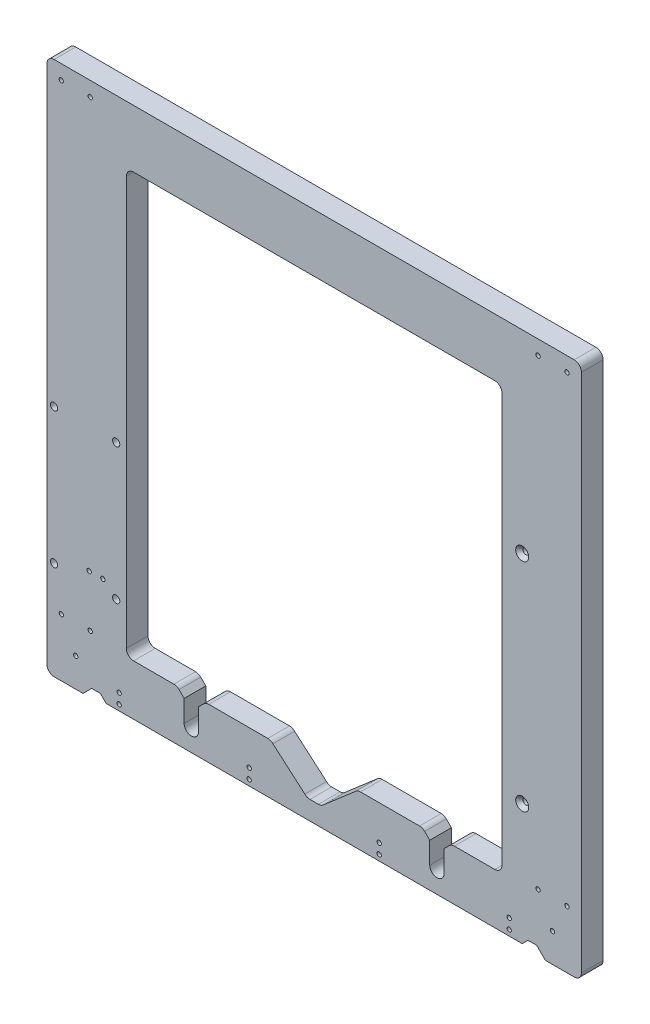
from build123d import *

# Parameters (mm, degrees)
MODEL_R                  = 1.5
MODEL_R_2                = 2
RESSALTO_EXTRUS_O1_DEPTH = 15
ESBO_O1_R                = 2.5
CORTE_EXTRUS_O1_DEPTH    = 10
ESBO_O2_R                = 2.5
CORTE_EXTRUS_O2_DEPTH    = 10
CHANFRO1_SIZE            = 2.5


with BuildPart() as part:
    # Model → Ressalto-extrusão1 (new body)
    with BuildSketch(Plane.XY):
        with BuildLine():
            Line((45.959420932, 55.536238099), (45.959420932, 415.536238099))
            ThreePointArc((45.959420932, 415.536238099), (47.423887026, 419.071772005), (50.959420932, 420.536238099))
            Line((50.959420932, 420.536238099), (410.959420932, 420.536238099))
            ThreePointArc((410.959420932, 420.536238099), (414.494954838, 419.071772005), (415.959420932, 415.536238099))
            Line((415.959420932, 415.536238099), (415.959420932, 55.536238099))
            ThreePointArc((415.959420932, 55.536238099), (414.494954838, 52.000704193), (410.959420932, 50.536238099))
            Line((410.959420932, 50.536238099), (390.959420932, 50.536238099))
            Line((390.959420932, 50.536238099), (388.959420932, 52.536238099))
            Line((388.959420932, 52.536238099), (384.959420932, 56.536238099))
            Line((384.959420932, 56.536238099), (378.959420932, 56.536238099))
            Line((378.959420932, 56.536238099), (374.959420932, 52.536238099))
            Line((374.959420932, 52.536238099), (86.959420932, 52.536238099))
            Line((86.959420932, 52.536238099), (82.959420932, 56.536238099))
            Line((82.959420932, 56.536238099), (76.959420932, 56.536238099))
            Line((76.959420932, 56.536238099), (72.959420932, 52.536238099))
            Line((72.959420932, 52.536238099), (70.959420932, 50.536238099))
            Line((70.959420932, 50.536238099), (50.959420932, 50.536238099))
            ThreePointArc((50.959420932, 50.536238099), (47.423887026, 52.000704193), (45.959420932, 55.536238099))
        make_face()
        with Locations((95.959420932, 56.536238099)):
            Circle(MODEL_R, mode=Mode.SUBTRACT)
        with Locations((365.959420932, 56.536238099)):
            Circle(MODEL_R, mode=Mode.SUBTRACT)
        with Locations((275.959420932, 56.536238099)):
            Circle(MODEL_R, mode=Mode.SUBTRACT)
        with Locations((185.959420932, 56.536238099)):
            Circle(MODEL_R, mode=Mode.SUBTRACT)
        with Locations((55.959420932, 90.536238099)):
            Circle(MODEL_R, mode=Mode.SUBTRACT)
        with Locations((75.959420932, 90.536238099)):
            Circle(MODEL_R, mode=Mode.SUBTRACT)
        with Locations((65.959420932, 70.536238099)):
            Circle(MODEL_R, mode=Mode.SUBTRACT)
        with Locations((395.959420932, 70.536238099)):
            Circle(MODEL_R, mode=Mode.SUBTRACT)
        with Locations((385.959420932, 90.536238099)):
            Circle(MODEL_R, mode=Mode.SUBTRACT)
        with Locations((405.959420932, 90.536238099)):
            Circle(MODEL_R, mode=Mode.SUBTRACT)
        with Locations((405.959420932, 410.536238099)):
            Circle(MODEL_R, mode=Mode.SUBTRACT)
        with Locations((385.959420932, 410.536238099)):
            Circle(MODEL_R, mode=Mode.SUBTRACT)
        with Locations((55.959420932, 410.536238099)):
            Circle(MODEL_R, mode=Mode.SUBTRACT)
        with Locations((75.959420932, 410.536238099)):
            Circle(MODEL_R, mode=Mode.SUBTRACT)
        with Locations((93.910965405, 118.501571518)):
            Circle(MODEL_R, mode=Mode.SUBTRACT)
        with Locations((50.910965405, 212.501571518)):
            Circle(MODEL_R, mode=Mode.SUBTRACT)
        with Locations((93.910965405, 212.501571518)):
            Circle(MODEL_R, mode=Mode.SUBTRACT)
        with Locations((50.876198806, 118.527793034)):
            Circle(MODEL_R, mode=Mode.SUBTRACT)
        with Locations((95.959420932, 63.536238099)):
            Circle(MODEL_R, mode=Mode.SUBTRACT)
        with Locations((365.959420932, 63.536238099)):
            Circle(MODEL_R, mode=Mode.SUBTRACT)
        with Locations((275.959420932, 63.536238099)):
            Circle(MODEL_R, mode=Mode.SUBTRACT)
        with Locations((185.959420932, 63.536238099)):
            Circle(MODEL_R, mode=Mode.SUBTRACT)
        with Locations((84.709420932, 126.036238099)):
            Circle(MODEL_R, mode=Mode.SUBTRACT)
        with Locations((75.209420932, 126.036238099)):
            Circle(MODEL_R, mode=Mode.SUBTRACT)
        with Locations((374.959420932, 136.436238099)):
            Circle(MODEL_R_2, mode=Mode.SUBTRACT)
        with Locations((374.959420932, 286.436238099)):
            Circle(MODEL_R_2, mode=Mode.SUBTRACT)
        with BuildLine():
            Line((140.959420932, 67.536238099), (140.959420932, 82.536238099))
            Line((140.959420932, 82.536238099), (137.423887026, 86.071772005))
            ThreePointArc((137.423887026, 86.071772005), (135.801770282, 87.155635761), (133.88835312, 87.536238099))
            Line((133.88835312, 87.536238099), (105.959420932, 87.536238099))
            ThreePointArc((105.959420932, 87.536238099), (102.423887026, 89.000704193), (100.959420932, 92.536238099))
            Line((100.959420932, 92.536238099), (100.959420932, 375.536238099))
            ThreePointArc((100.959420932, 375.536238099), (102.423887026, 379.071772005), (105.959420932, 380.536238099))
            Line((105.959420932, 380.536238099), (355.959420932, 380.536238099))
            ThreePointArc((355.959420932, 380.536238099), (359.494954838, 379.071772005), (360.959420932, 375.536238099))
            Line((360.959420932, 375.536238099), (360.959420932, 92.536238099))
            ThreePointArc((360.959420932, 92.536238099), (359.494954838, 89.000704193), (355.959420932, 87.536238099))
            Line((355.959420932, 87.536238099), (328.030488744, 87.536238099))
            ThreePointArc((328.030488744, 87.536238099), (326.117071582, 87.155635761), (324.494954838, 86.071772005))
            Line((324.494954838, 86.071772005), (320.959420932, 82.536238099))
            Line((320.959420932, 82.536238099), (320.959420932, 67.536238099))
            ThreePointArc((320.959420932, 67.536238099), (315.959420932, 62.536238099), (310.959420932, 67.536238099))
            Line((310.959420932, 67.536238099), (310.959420932, 82.536238099))
            Line((310.959420932, 82.536238099), (307.423887026, 86.071772005))
            ThreePointArc((307.423887026, 86.071772005), (305.801770282, 87.155635761), (303.88835312, 87.536238099))
            Line((303.88835312, 87.536238099), (263.030488744, 87.536238099))
            ThreePointArc((263.030488744, 87.536238099), (261.117071582, 87.155635761), (259.494954838, 86.071772005))
            Line((259.494954838, 86.071772005), (237.423887026, 67.000704193))
            ThreePointArc((237.423887026, 67.000704193), (235.801770282, 65.916840436), (233.88835312, 65.536238099))
            Line((233.88835312, 65.536238099), (228.030488744, 65.536238099))
            ThreePointArc((228.030488744, 65.536238099), (226.117071582, 65.916840436), (224.494954838, 67.000704193))
            Line((224.494954838, 67.000704193), (202.423887026, 86.071772005))
            ThreePointArc((202.423887026, 86.071772005), (200.801770282, 87.155635761), (198.88835312, 87.536238099))
            Line((198.88835312, 87.536238099), (158.030488744, 87.536238099))
            ThreePointArc((158.030488744, 87.536238099), (156.117071582, 87.155635761), (154.494954838, 86.071772005))
            Line((154.494954838, 86.071772005), (150.959420932, 82.536238099))
            Line((150.959420932, 82.536238099), (150.959420932, 67.536238099))
            ThreePointArc((150.959420932, 67.536238099), (145.959420932, 62.536238099), (140.959420932, 67.536238099))
        make_face(mode=Mode.SUBTRACT)
    extrude(amount=RESSALTO_EXTRUS_O1_DEPTH)

    # Esboço1 → Corte-extrusão1 (cut)
    with BuildSketch(Plane(origin=(0, 0, 0), x_dir=(-1, 0, 0), z_dir=(0, 0, -1))):
        with Locations((-385.959420932, 90.536238099)):
            Circle(ESBO_O1_R)
        with Locations((-405.959420932, 90.536238099)):
            Circle(ESBO_O1_R)
        with Locations((-395.959420932, 70.536238099)):
            Circle(ESBO_O1_R)
        with Locations((-75.959420932, 90.536238099)):
            Circle(ESBO_O1_R)
        with Locations((-55.959420932, 90.536238099)):
            Circle(ESBO_O1_R)
        with Locations((-65.959420932, 70.536238099)):
            Circle(ESBO_O1_R)
        with Locations((-405.959420932, 410.536238099)):
            Circle(ESBO_O1_R)
        with Locations((-385.959420932, 410.536238099)):
            Circle(ESBO_O1_R)
        with Locations((-75.959420932, 410.536238099)):
            Circle(ESBO_O1_R)
        with Locations((-55.959420932, 410.536238099)):
            Circle(ESBO_O1_R)
        with Locations((-84.709420932, 126.036238099)):
            Circle(ESBO_O1_R)
        with Locations((-75.209420932, 126.036238099)):
            Circle(ESBO_O1_R)
    extrude(amount=-CORTE_EXTRUS_O1_DEPTH, mode=Mode.SUBTRACT)

    # Esboço2 → Corte-extrusão2 (cut)
    with BuildSketch(Plane.XY.offset(15)):
        with Locations((50.910965405, 212.501571518)):
            Circle(ESBO_O2_R)
        with Locations((93.910965405, 212.501571518)):
            Circle(ESBO_O2_R)
        with Locations((93.910965405, 118.501571518)):
            Circle(ESBO_O2_R)
        with Locations((50.876198806, 118.527793034)):
            Circle(ESBO_O2_R)
    extrude(amount=-CORTE_EXTRUS_O2_DEPTH, mode=Mode.SUBTRACT)

    # Chanfro1
    chanfro1_edges = [part.edges().sort_by_distance(p)[0] for p in [
        (372.959420932, 136.436238099, 15),
        (372.959420932, 286.436238099, 15),
    ]]
    chamfer(chanfro1_edges, length=CHANFRO1_SIZE)


solid = part.part
